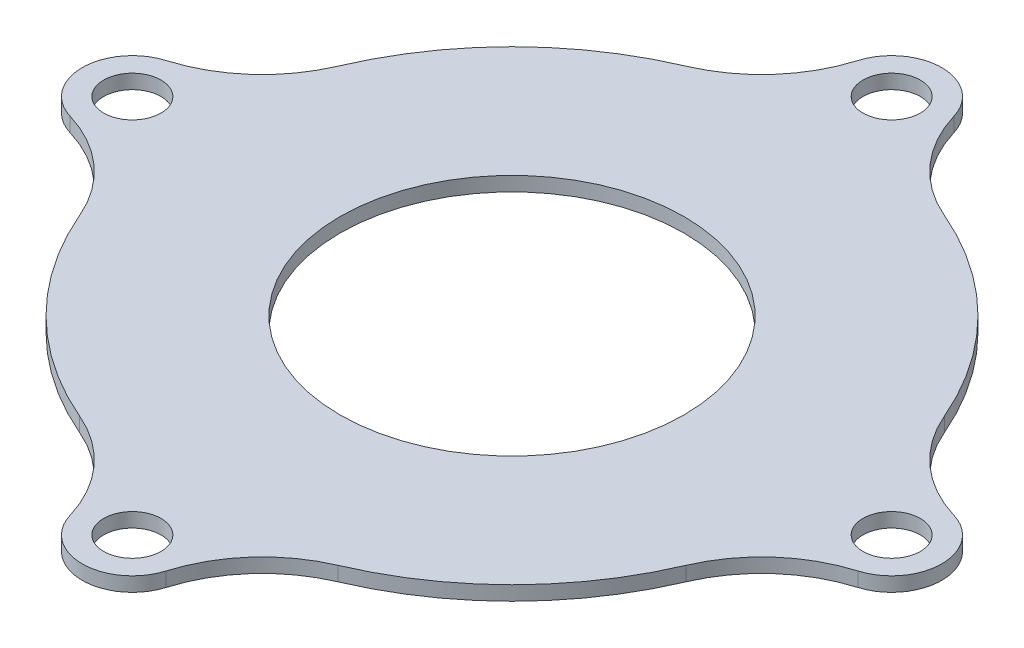
from build123d import *

# Parameters (mm, degrees)
SKETCH1_R           = 23
BOSS_EXTRUDE1_DEPTH = 3
SKETCH2_R           = 12
CUT_EXTRUDE1_DEPTH  = 10
SKETCH3_R           = 1.75
BOSS_EXTRUDE2_DEPTH = 3
SKETCH4_R           = 2.8
CUT_EXTRUDE2_DEPTH  = 1
FILLET1_R           = 10
SKETCH5_R           = 31.123463038
CUT_EXTRUDE3_DEPTH  = 1
CUT_EXTRUDE4_DEPTH  = 1
SKETCH7_R           = 2.8
SKETCH7_R_2         = 2
BOSS_EXTRUDE3_DEPTH = 1


with BuildPart() as part:
    # Sketch1 → Boss-Extrude1 (new body)
    with BuildSketch(Plane(origin=(0, 0, 0), x_dir=(1, 0, 0), z_dir=(0, 1, 0))):
        Circle(SKETCH1_R)
    extrude(amount=BOSS_EXTRUDE1_DEPTH)

    # Sketch2 → Cut-Extrude1 (cut)
    with BuildSketch(Plane.XZ):
        Circle(SKETCH2_R)
    extrude(amount=-CUT_EXTRUDE1_DEPTH, mode=Mode.SUBTRACT)

    # Sketch3 → Boss-Extrude2 (add)
    with BuildSketch(Plane.XZ):
        with BuildLine():
            Line((-26.5, 3.5), (-22.732135843, 3.5))
            ThreePointArc((-22.732135843, 3.5), (-23, 0), (-22.732135843, -3.5))
            Line((-22.732135843, -3.5), (-26.5, -3.5))
            ThreePointArc((-26.5, -3.5), (-30, 0), (-26.5, 3.5))
        make_face()
        with Locations((-26.5, 0)):
            Circle(SKETCH3_R, mode=Mode.SUBTRACT)
        with BuildLine():
            Line((3.5, 26.5), (3.5, 22.732135843))
            ThreePointArc((3.5, 22.732135843), (0, 23), (-3.5, 22.732135843))
            Line((-3.5, 22.732135843), (-3.5, 26.5))
            ThreePointArc((-3.5, 26.5), (0, 30), (3.5, 26.5))
        make_face()
        with Locations((0, 26.5)):
            Circle(SKETCH3_R, mode=Mode.SUBTRACT)
        with BuildLine():
            Line((26.5, -3.5), (22.732135843, -3.5))
            ThreePointArc((22.732135843, -3.5), (23, 0), (22.732135843, 3.5))
            Line((22.732135843, 3.5), (26.5, 3.5))
            ThreePointArc((26.5, 3.5), (30, 0), (26.5, -3.5))
        make_face()
        with Locations((26.5, 0)):
            Circle(SKETCH3_R, mode=Mode.SUBTRACT)
        with BuildLine():
            Line((-3.5, -26.5), (-3.5, -22.732135843))
            ThreePointArc((-3.5, -22.732135843), (0, -23), (3.5, -22.732135843))
            Line((3.5, -22.732135843), (3.5, -26.5))
            ThreePointArc((3.5, -26.5), (0, -30), (-3.5, -26.5))
        make_face()
        with Locations((0, -26.5)):
            Circle(SKETCH3_R, mode=Mode.SUBTRACT)
    extrude(amount=-BOSS_EXTRUDE2_DEPTH)

    # Sketch4 → Cut-Extrude2 (cut)
    with BuildSketch(Plane.XZ):
        with Locations((-26.5, 0)):
            Circle(SKETCH4_R)
        with Locations((0, 26.5)):
            Circle(SKETCH4_R)
        with Locations((26.5, 0)):
            Circle(SKETCH4_R)
        with Locations((0, -26.5)):
            Circle(SKETCH4_R)
    extrude(amount=-CUT_EXTRUDE2_DEPTH, mode=Mode.SUBTRACT)

    # Fillet1
    fillet1_edges = [part.edges().sort_by_distance(p)[0] for p in [
        (3.5, 1.5, 22.732135843),
        (22.732135843, 1.5, 3.5),
        (22.732135843, 1.5, -3.5),
        (3.5, 1.5, -22.732135843),
        (-3.5, 1.5, -22.732135843),
        (-22.732135843, 1.5, -3.5),
        (-22.732135843, 1.5, 3.5),
        (-3.5, 1.5, 22.732135843),
    ]]
    fillet(fillet1_edges, radius=FILLET1_R)

    # Sketch5 → Cut-Extrude3 (cut)
    with BuildSketch(Plane(origin=(0, 3, 0), x_dir=(1, 0, 0), z_dir=(0, 1, 0))):
        Circle(SKETCH5_R)
    extrude(amount=-CUT_EXTRUDE3_DEPTH, mode=Mode.SUBTRACT)

    # Sketch6 → Cut-Extrude4 (cut)
    with BuildSketch(Plane(origin=(0, 2, 0), x_dir=(1, 0, 0), z_dir=(0, 1, 0))):
        with BuildLine():
            ThreePointArc((3.353997774, 27.500349406), (5.477838975, 23.697921815), (9.016591418, 21.15894797))
            ThreePointArc((9.016591418, 21.15894797), (16.263455967, 16.263455967), (21.15894797, 9.016591418))
            ThreePointArc((21.15894797, 9.016591418), (23.697921815, 5.477838975), (27.500349406, 3.353997774))
            ThreePointArc((27.500349406, 3.353997774), (30, 0), (27.500349406, -3.353997774))
            ThreePointArc((27.500349406, -3.353997774), (23.697921815, -5.477838975), (21.15894797, -9.016591418))
            ThreePointArc((21.15894797, -9.016591418), (16.263455967, -16.263455967), (9.016591418, -21.15894797))
            ThreePointArc((9.016591418, -21.15894797), (5.477838975, -23.697921815), (3.353997774, -27.500349406))
            ThreePointArc((3.353997774, -27.500349406), (0, -30), (-3.353997774, -27.500349406))
            ThreePointArc((-3.353997774, -27.500349406), (-5.477838975, -23.697921815), (-9.016591418, -21.15894797))
            ThreePointArc((-9.016591418, -21.15894797), (-16.263455967, -16.263455967), (-21.15894797, -9.016591418))
            ThreePointArc((-21.15894797, -9.016591418), (-23.697921815, -5.477838975), (-27.500349406, -3.353997774))
            ThreePointArc((-27.500349406, -3.353997774), (-30, 0), (-27.500349406, 3.353997774))
            ThreePointArc((-27.500349406, 3.353997774), (-23.697921815, 5.477838975), (-21.15894797, 9.016591418))
            ThreePointArc((-21.15894797, 9.016591418), (-16.263455967, 16.263455967), (-9.016591418, 21.15894797))
            ThreePointArc((-9.016591418, 21.15894797), (-5.477838975, 23.697921815), (-3.353997774, 27.500349406))
            ThreePointArc((-3.353997774, 27.500349406), (0, 30), (3.353997774, 27.500349406))
        make_face()
    extrude(amount=-CUT_EXTRUDE4_DEPTH, mode=Mode.SUBTRACT)

    # Sketch7 → Boss-Extrude3 (add)
    with BuildSketch(Plane.XZ):
        with Locations((0, 26.5)):
            Circle(SKETCH7_R)
        with Locations((0, 26.5)):
            Circle(SKETCH7_R_2, mode=Mode.SUBTRACT)
        with Locations((26.5, 0)):
            Circle(SKETCH7_R)
        with Locations((26.5, 0)):
            Circle(SKETCH7_R_2, mode=Mode.SUBTRACT)
        with Locations((0, -26.5)):
            Circle(SKETCH7_R)
        with Locations((0, -26.5)):
            Circle(SKETCH7_R_2, mode=Mode.SUBTRACT)
        with Locations((-26.5, 0)):
            Circle(SKETCH7_R)
        with Locations((-26.5, 0)):
            Circle(SKETCH7_R_2, mode=Mode.SUBTRACT)
    extrude(amount=-BOSS_EXTRUDE3_DEPTH)


solid = part.part
